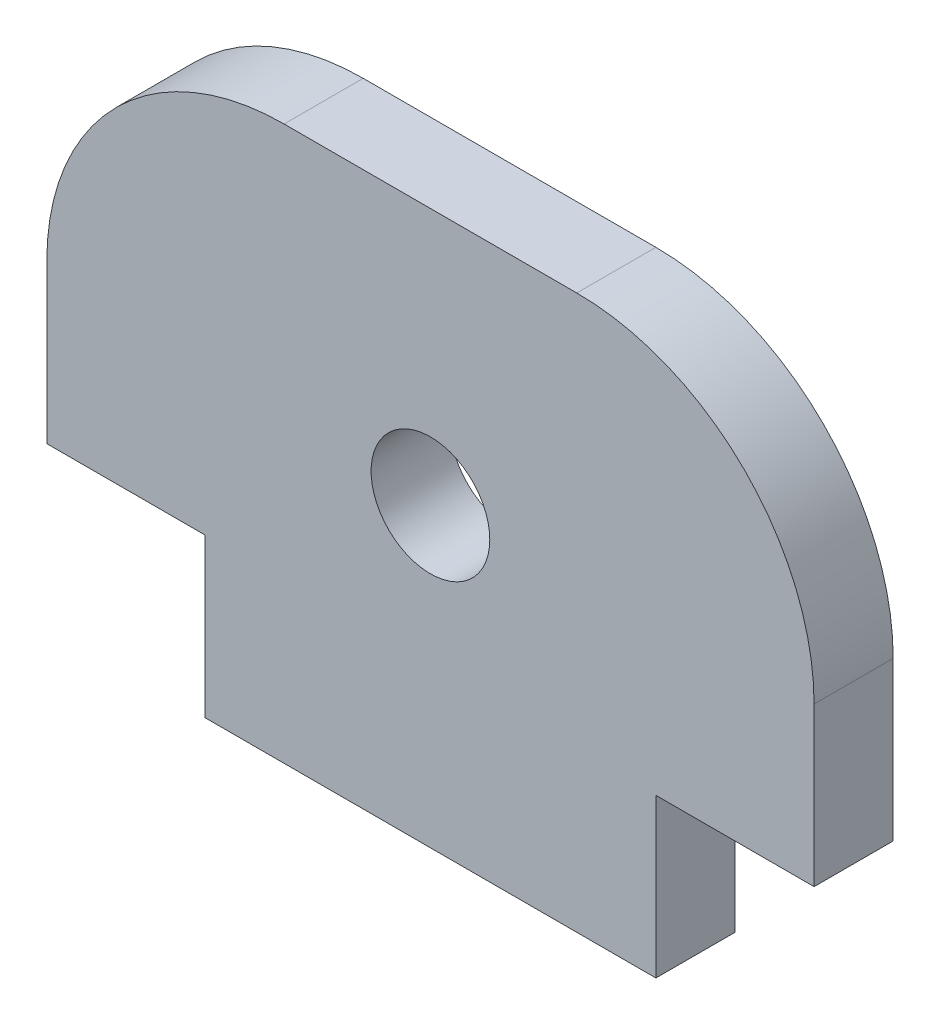
from build123d import *

# Parameters (mm, degrees)
MODEL_R             = 1.5
BOSS_EXTRUDE1_DEPTH = 2


with BuildPart() as part:
    # Model → Boss-Extrude1 (new body)
    with BuildSketch(Plane.XY):
        with BuildLine():
            Line((9.7, -3.5), (9.7, 0.5))
            ThreePointArc((9.7, 0.5), (7.942640687, 4.742640687), (3.7, 6.5))
            Line((3.7, 6.5), (-3.7, 6.5))
            ThreePointArc((-3.7, 6.5), (-7.942640687, 4.742640687), (-9.7, 0.5))
            Line((-9.7, 0.5), (-9.7, -3.5))
            Line((-9.7, -3.5), (-5.7, -3.5))
            Line((-5.7, -3.5), (-5.7, -7.5))
            Line((-5.7, -7.5), (5.7, -7.5))
            Line((5.7, -7.5), (5.7, -3.5))
            Line((5.7, -3.5), (9.7, -3.5))
        make_face()
        Circle(MODEL_R, mode=Mode.SUBTRACT)
    extrude(amount=BOSS_EXTRUDE1_DEPTH)


solid = part.part
